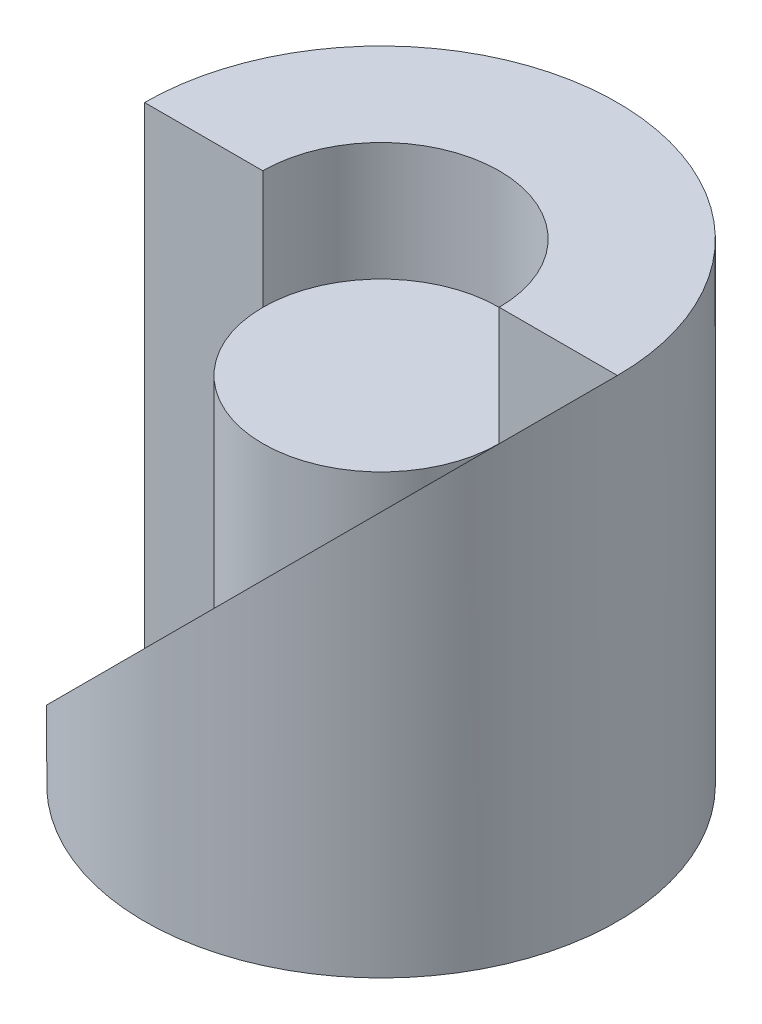
from build123d import *
from build123d.topology import SkipClean

# Parameters (mm, degrees)
SKETCH1_R           = 20
SKETCH1_R_2         = 10
BOSS_EXTRUDE3_DEPTH = 40
CUT_EXTRUDE2_DEPTH  = 40
SKETCH5_R           = 9.992609398
BOSS_EXTRUDE4_DEPTH = 30


with BuildPart() as part:
    # Sketch1 → Boss-Extrude3 (new body)
    with BuildSketch(Plane(origin=(0, 0, 0), x_dir=(1, 0, 0), z_dir=(0, 1, 0))):
        with Locations(Location((0, 0, 0), (0, 0, 270))):
            Circle(SKETCH1_R)
        with Locations(Location((0, 0, 0), (0, 0, 270))):
            Circle(SKETCH1_R_2, mode=Mode.SUBTRACT)
    extrude(amount=BOSS_EXTRUDE3_DEPTH)

    # Sketch4 → Cut-Extrude2 (cut)
    with SkipClean():  # the faces are left unmerged after this step: merging them gives an invalid solid
        with BuildSketch(Plane.XY):
            Polygon((-20, 0), (20, 40), (-20, 40), align=None)
        extrude(amount=CUT_EXTRUDE2_DEPTH, mode=Mode.SUBTRACT)


with BuildPart() as body_2:
    # Sketch5 → Boss-Extrude4 (new body)
    with BuildSketch(Plane(origin=(0, 0, 0), x_dir=(1, 0, 0), z_dir=(0, 1, 0))):
        with Locations(Location((0, 0, 0), (0, 0, 270))):
            Circle(SKETCH5_R)
    extrude(amount=BOSS_EXTRUDE4_DEPTH)


solid = Compound([part.part, body_2.part])
